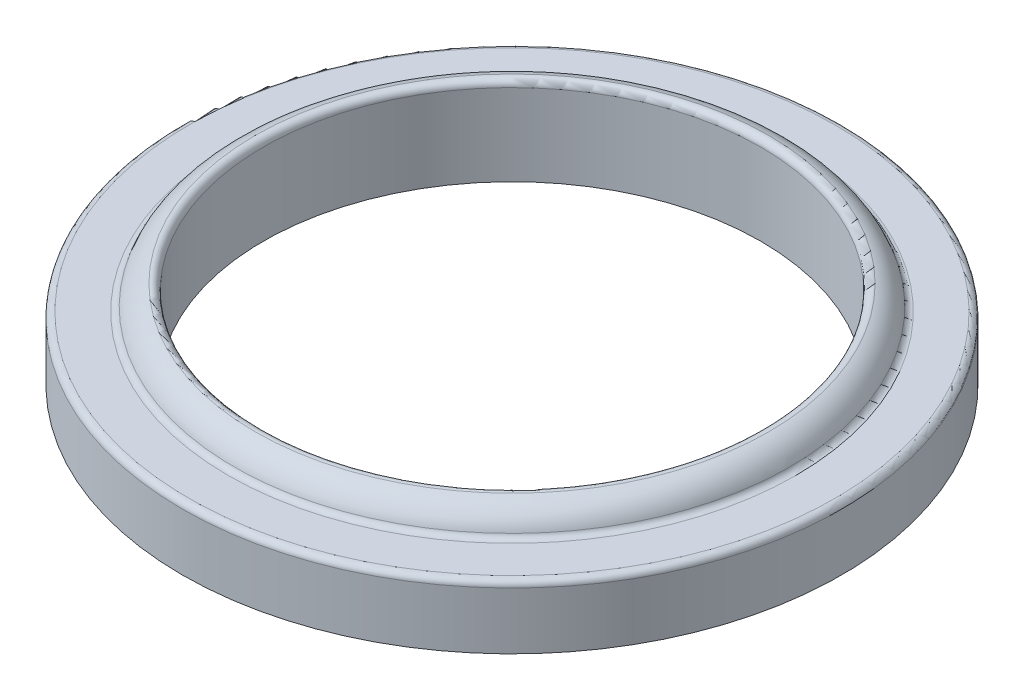
from build123d import *

# Parameters (mm, degrees)
FILLET1_R = 0.254


with BuildPart() as part:
    # Sketch1 → Revolve1 (revolve)
    with BuildSketch(Plane.XY):
        with BuildLine():
            Line((-9.9695, 0), (-9.9695, 3.556))
            ThreePointArc((-9.9695, 3.556), (-10.758153639, 3.268166821), (-11.176, 2.54))
            Line((-11.176, 2.54), (-13.208, 2.54))
            Line((-13.208, 2.54), (-13.208, 0))
            Line((-13.208, 0), (-9.9695, 0))
        make_face()
    revolve(axis=Axis((0, 0, 0), (0, 1, 0)))

    # Fillet1
    fillet1_edges = [part.edges().sort_by_distance(p)[0] for p in [
        (13.208, 2.54, 0),
        (11.176, 2.54, 0),
        (9.9695, 3.556, 0),
    ]]
    fillet(fillet1_edges, radius=FILLET1_R)


solid = part.part
